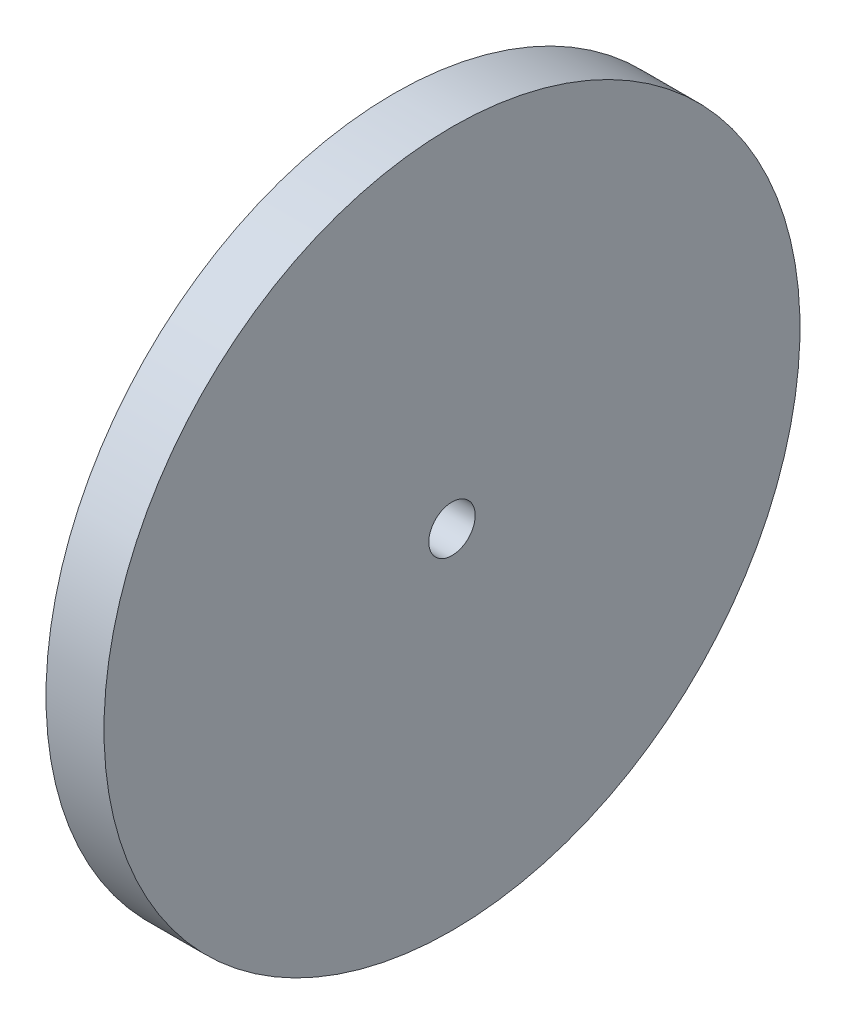
from build123d import *

# Parameters (mm, degrees)
SKETCH2_R          = 1
CUT_EXTRUDE1_DEPTH = 26
SKETCH3_R          = 15
CUT_EXTRUDE2_DEPTH = 22.5


with BuildPart() as part:
    # Sketch1 → Revolve1 (revolve)
    with BuildSketch(Plane.XY):
        with BuildLine():
            Line((-12.5, 15), (-12.5, 0))
            Line((-12.5, 0), (12.5, 0))
            Line((12.5, 0), (12.5, 15))
            Line((12.5, 15), (10, 15))
            ThreePointArc((10, 15), (0, 5), (-10, 15))
            Line((-10, 15), (-12.5, 15))
        make_face()
    revolve(axis=Axis((-12.5, 0, 0), (1, 0, 0)))

    # Sketch2 → Cut-Extrude1 (cut, through all)
    with BuildSketch(Plane(origin=(12.5, 0, 0), x_dir=(0, 0, -1), z_dir=(1, 0, 0))):
        Circle(SKETCH2_R)
    extrude(amount=-CUT_EXTRUDE1_DEPTH, mode=Mode.SUBTRACT)

    # Sketch3 → Cut-Extrude2 (cut)
    with BuildSketch(Plane(origin=(12.5, 0, 0), x_dir=(0, 0, -1), z_dir=(1, 0, 0))):
        Circle(SKETCH3_R)
    extrude(amount=-CUT_EXTRUDE2_DEPTH, mode=Mode.SUBTRACT)


solid = part.part
